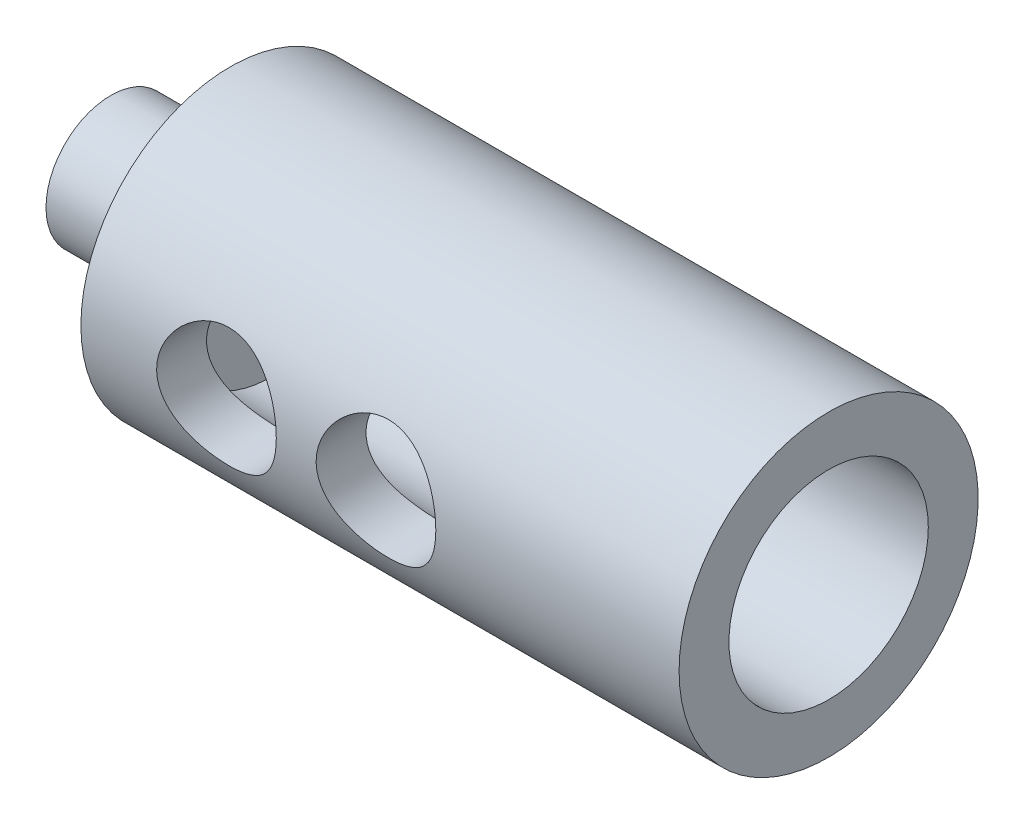
from build123d import *

# Parameters (mm, degrees)
F_6_0_6_DIAMETER_HOLE3_D           = 6
F_6_0_6_DIAMETER_HOLE3_ON_FACE_2_D = 6
SKETCH7_R                          = 5
CUT_EXTRUDE1_DEPTH                 = 28


with BuildPart() as part:
    # Sketch1 → Revolve2 (revolve)
    with BuildSketch(Plane.XY):
        Polygon((0, 0), (-6, 0), (-6, -1.5), (2, -1.5), (2, 0.25), (28, 0.25), (28, -3.25), (30, -3.25), (30, 4.25), (0, 4.25), align=None)
    revolve(axis=Axis((-6, -3.25, 0), (1, 0, 0)))

    # Ø6.0 (6) Diameter Hole3 (through all)
    with Locations(Plane(origin=(6.798989942, -3.243014935, 7.499996747), x_dir=(0, 0.999999566, -0.000931342), z_dir=(0, 0.000931342, 0.999999566))):
        with Locations((0, 0)):
            Hole(F_6_0_6_DIAMETER_HOLE3_D / 2)

    # Ø6.0 (6) Diameter Hole3 on face 2 (through all)
    with Locations(Plane(origin=(14.798989942, -3.243014935, 7.499996747), x_dir=(0, 0.999999567, -0.000931), z_dir=(0, 0.000931, 0.999999567))):
        with Locations((0, 0)):
            Hole(F_6_0_6_DIAMETER_HOLE3_ON_FACE_2_D / 2)

    # Sketch7 → Cut-Extrude1 (cut)
    with BuildSketch(Plane(origin=(30, 0, 0), x_dir=(0, 0, -1), z_dir=(1, 0, 0))):
        with Locations((0, -3.25)):
            Circle(SKETCH7_R)
    extrude(amount=-CUT_EXTRUDE1_DEPTH, mode=Mode.SUBTRACT)


solid = part.part
